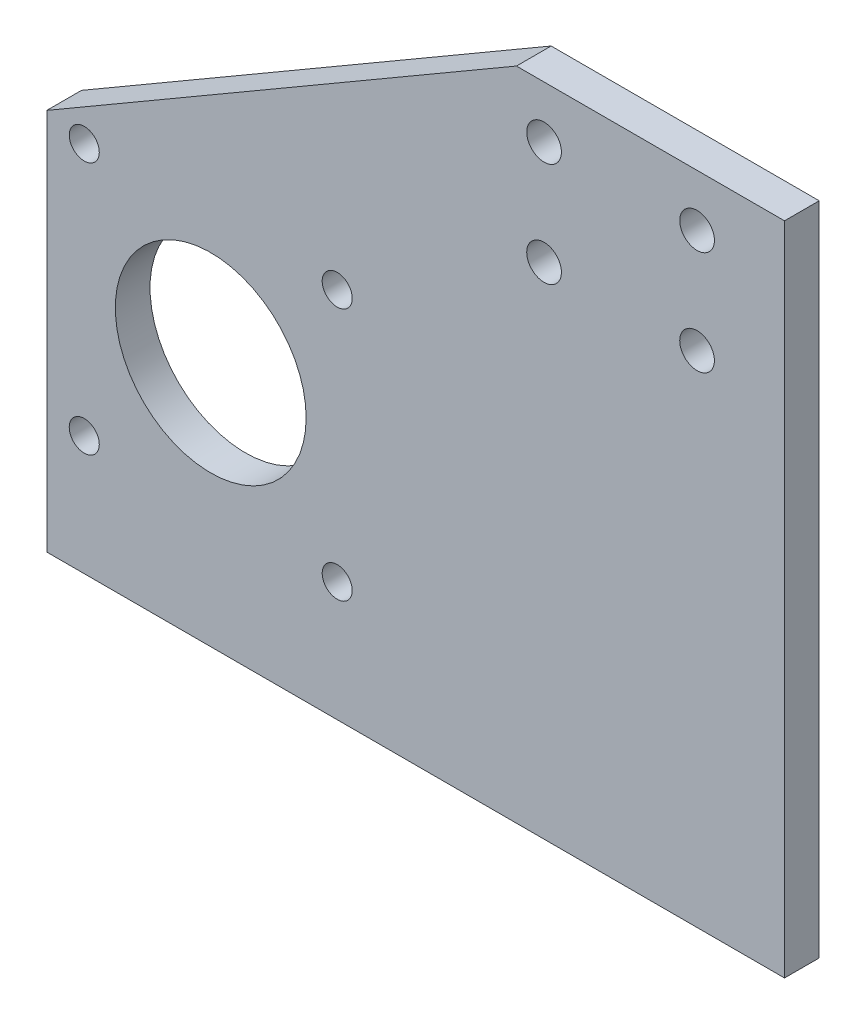
from build123d import *

# Parameters (mm, degrees)
CROQUIS1_R              = 3.175
SALIENTE_EXTRUIR1_DEPTH = 6.35
CROQUIS2_R              = 2.75
CROQUIS2_R_2            = 17.4625
CORTAR_EXTRUIR1_DEPTH   = 12.7


with BuildPart() as part:
    # Croquis1 → Saliente-Extruir1 (new body)
    with BuildSketch(Plane.XY):
        Polygon((0, 0), (-135, 0), (-135, 70), (-49.056075443, 120), (0, 120), align=None)
        with Locations((-44, 110.475)):
            Circle(CROQUIS1_R, mode=Mode.SUBTRACT)
        with Locations((-16, 110.475)):
            Circle(CROQUIS1_R, mode=Mode.SUBTRACT)
        with Locations((-16, 91.425)):
            Circle(CROQUIS1_R, mode=Mode.SUBTRACT)
        with Locations((-44, 91.425)):
            Circle(CROQUIS1_R, mode=Mode.SUBTRACT)
    extrude(amount=SALIENTE_EXTRUIR1_DEPTH)

    # Croquis2 → Cortar-Extruir1 (cut)
    with BuildSketch(Plane.XY.offset(6.35)):
        with Locations((-128.145, 68.15)):
            Circle(CROQUIS2_R)
        with Locations((-128.145, 21.85)):
            Circle(CROQUIS2_R)
        with Locations((-81.855, 21.85)):
            Circle(CROQUIS2_R)
        with Locations((-81.855, 68.15)):
            Circle(CROQUIS2_R)
        with Locations((-105, 45)):
            Circle(CROQUIS2_R_2)
    extrude(amount=-CORTAR_EXTRUIR1_DEPTH, mode=Mode.SUBTRACT)


solid = part.part
